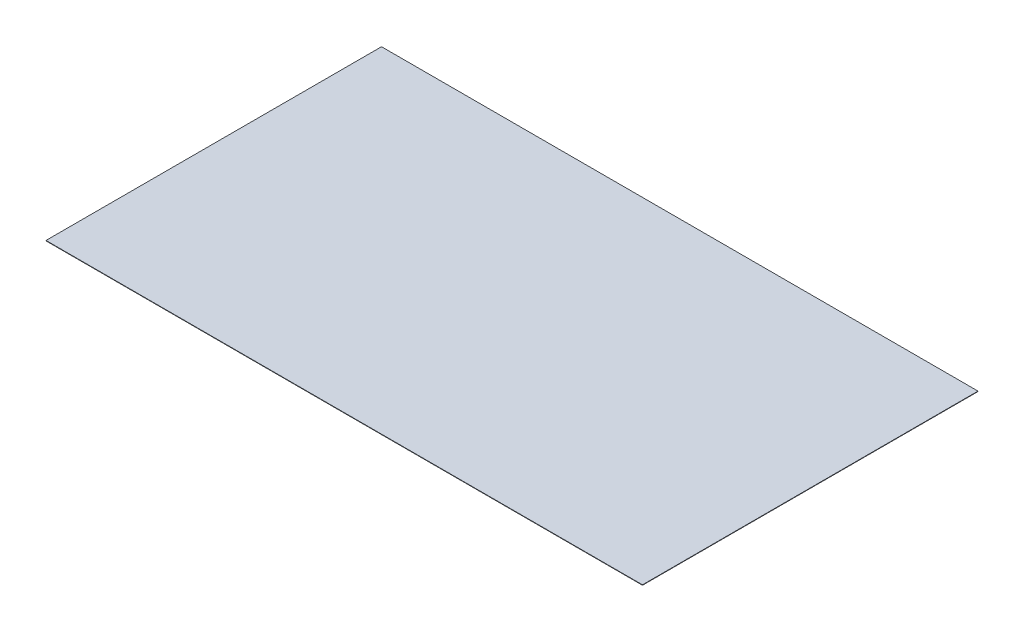
from build123d import *

# Parameters (mm, degrees)
SKETCH1_W           = 3657.6
SKETCH1_H           = 2057.4
BOSS_EXTRUDE1_DEPTH = 2.54


with BuildPart() as part:
    # Sketch1 → Boss-Extrude1 (new body)
    with BuildSketch(Plane(origin=(0, 0, 0), x_dir=(1, 0, 0), z_dir=(0, 1, 0))):
        with Locations((1828.8, -1028.7)):
            Rectangle(SKETCH1_W, SKETCH1_H)
    extrude(amount=BOSS_EXTRUDE1_DEPTH)


solid = part.part
